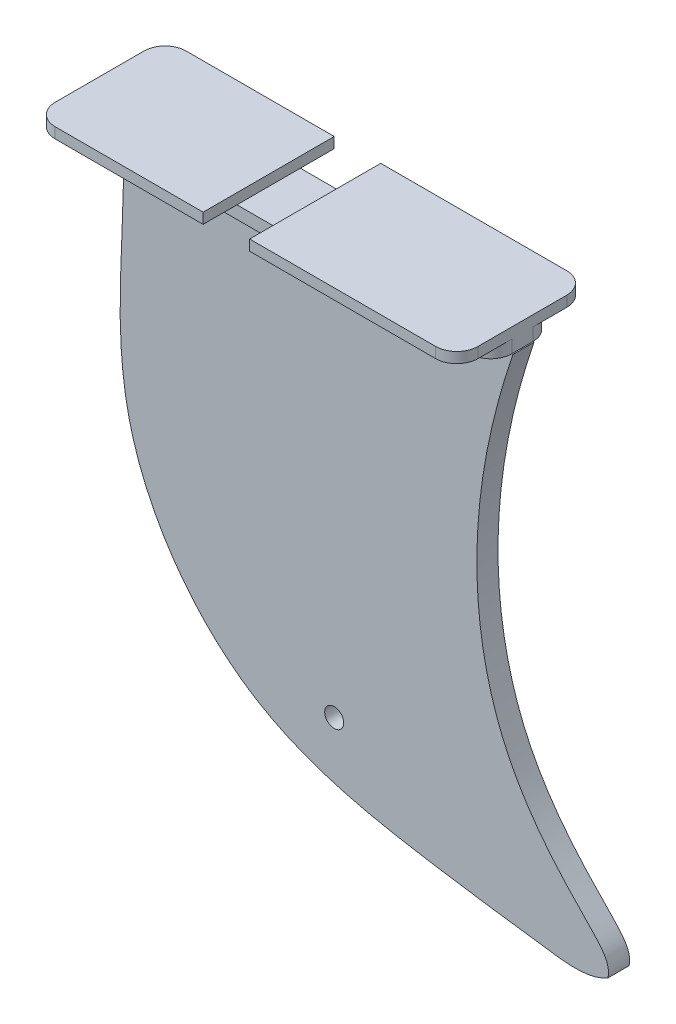
from build123d import *

# Parameters (mm, degrees)
CROQUIS1_W              = 100
CROQUIS1_H              = 31
SALIENTE_EXTRUIR1_DEPTH = 2.5
CROQUIS2_W              = 92
CROQUIS2_H              = 15
SALIENTE_EXTRUIR2_DEPTH = 3
REDONDEO1_R             = 5
SALIENTE_EXTRUIR3_DEPTH = 2.5
CROQUIS4_R              = 2.25
CORTAR_EXTRUIR1_DEPTH   = 5
CROQUIS5_W              = 11
CROQUIS5_H              = 2.5
CORTAR_EXTRUIR2_DEPTH   = 32


with BuildPart() as part:
    # Croquis1 → Saliente-Extruir1 (new body)
    with BuildSketch(Plane(origin=(0, 0, 0), x_dir=(1, 0, 0), z_dir=(0, 1, 0))):
        Rectangle(CROQUIS1_W, CROQUIS1_H)
    extrude(amount=SALIENTE_EXTRUIR1_DEPTH)

    # Croquis2 → Saliente-Extruir2 (add)
    with BuildSketch(Plane.XZ):
        with Locations((4, 0)):
            Rectangle(CROQUIS2_W, CROQUIS2_H)
    extrude(amount=SALIENTE_EXTRUIR2_DEPTH)

    # Redondeo1
    redondeo1_edges = [part.edges().sort_by_distance(p)[0] for p in [
        (50, -1.5, -7.5),
        (50, -1.5, 7.5),
        (-42, -1.5, 7.5),
        (-42, -1.5, -7.5),
        (50, 1.25, 15.5),
        (-50, 1.25, 15.5),
        (-50, 1.25, -15.5),
        (50, 1.25, -15.5),
    ]]
    fillet(redondeo1_edges, radius=REDONDEO1_R)

    # Croquis3 → Saliente-Extruir3 (add, symmetric)
    with BuildSketch(Plane.XY):
        with BuildLine():
            Line((50.268673777, -3), (-42, -3))
            add(Edge.make_bspline(
                [(-42, -3), (-40.908513064, -23.29428707), (-48.776278563, -61.439241492), (-15.011612903, -108.496757753), (26.091280983, -116.271998862), (53.921744721, -120.172870924), (68.330972256, -122.076661229), (72.745319056, -119.457978538)],
                knots=[0, 0, 0, 0, 0.313172426, 0.560686791, 0.787562365, 0.924725026, 1, 1, 1, 1], degree=3))
            add(Edge.make_bspline(
                [(72.745319056, -119.457978538), (73.5272978, -115.295050348), (67.866383472, -111.564174063), (40.837413629, -79.656102563), (38.369873508, -37.789508287), (50.268673777, -3)],
                knots=[0, 0, 0, 0, 0.326988998, 0.554852248, 1, 1, 1, 1], degree=3))
        make_face()
    extrude(amount=SALIENTE_EXTRUIR3_DEPTH, both=True)

    # Croquis4 → Cortar-Extruir1 (cut)
    with BuildSketch(Plane.XY.offset(2.5)):
        with Locations((8, -8.5)):
            Circle(CROQUIS4_R)
        with Locations((8, -98.5)):
            Circle(CROQUIS4_R)
    extrude(amount=-CORTAR_EXTRUIR1_DEPTH, mode=Mode.SUBTRACT)

    # Croquis5 → Cortar-Extruir2 (cut, through all)
    with BuildSketch(Plane.XY.offset(15.5)):
        with Locations((-4.5, 1.25)):
            Rectangle(CROQUIS5_W, CROQUIS5_H)
    extrude(amount=-CORTAR_EXTRUIR2_DEPTH, mode=Mode.SUBTRACT)


solid = part.part
